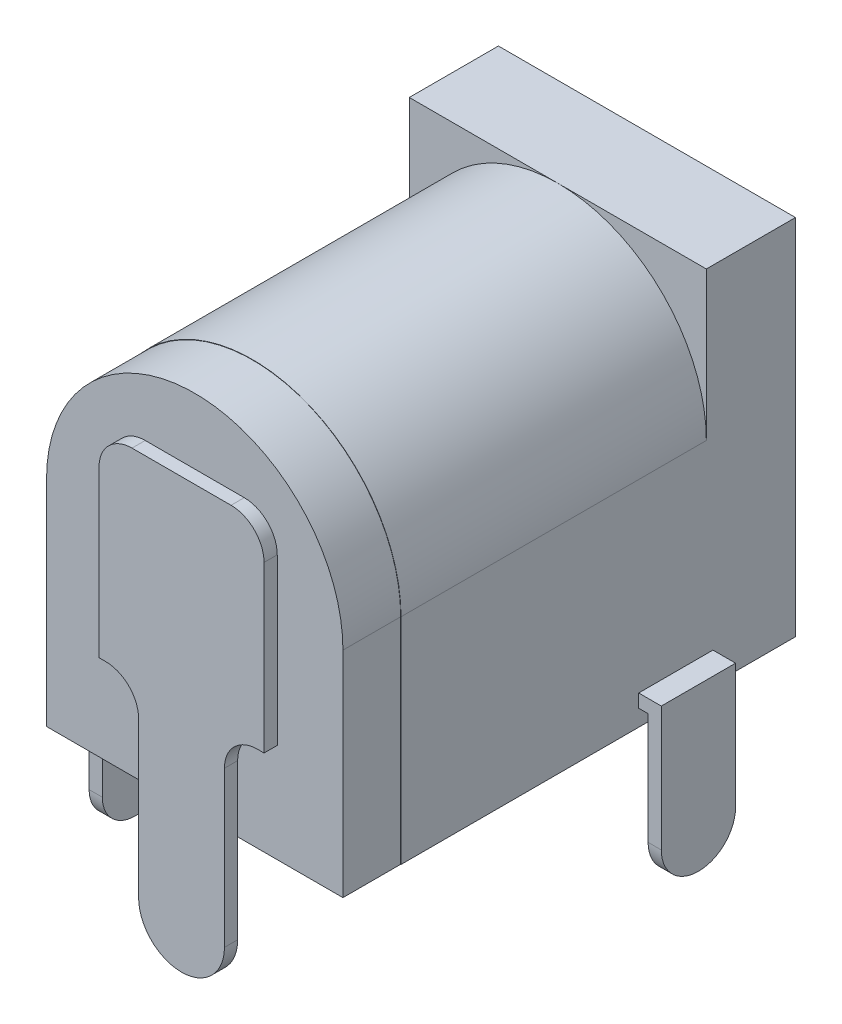
from build123d import *

# Parameters (mm, degrees)
EXTRUSION1_DEPTH        = 9.25
EXTRUSION2_DEPTH        = 1.75
ESQUISSE3_W             = 9
ESQUISSE3_H             = 11
EXTRUSION3_DEPTH        = 2.7
ESQUISSE5_R             = 3.1
ENL_V_MAT_EXTRU_1_DEPTH = 10
ESQUISSE6_R             = 1
EXTRUSION4_DEPTH        = 8
CONG_1_R                = 0.99
EXTRUSION5_DEPTH        = 0.4
ESQUISSE8_W             = 2.25
ESQUISSE8_H             = 0.4
CONG_2_R                = 1.124
ESQUISSE10_W            = 2
ESQUISSE10_H            = 0.4
CONG_3_R                = 0.99


with BuildPart() as part:
    # Esquisse1 → Extrusion1 (new body)
    with BuildSketch(Plane.XY):
        with BuildLine():
            Line((4.5, 6.5), (4.5, 0))
            Line((4.5, 0), (-4.5, 0))
            Line((-4.5, 0), (-4.5, 6.5))
            ThreePointArc((-4.5, 6.5), (0, 11), (4.5, 6.5))
        make_face()
    extrude(amount=EXTRUSION1_DEPTH)

    # Esquisse2 → Extrusion2 (add)
    with BuildSketch(Plane.XY.offset(9.25)):
        with BuildLine():
            Line((4.489996356, 6.494279339), (4.490003644, 0))
            Line((4.490003644, 0), (-4.49, 0))
            Line((-4.49, 0), (-4.49, 6.5))
            ThreePointArc((-4.49, 6.5), (0.002860331, 10.989999089), (4.489996356, 6.494279339))
        make_face()
    extrude(amount=EXTRUSION2_DEPTH)

    # Esquisse3 → Extrusion3 (add)
    with BuildSketch(Plane(origin=(0, 0, 0), x_dir=(-1, 0, 0), z_dir=(0, 0, -1))):
        with Locations((0, 5.5)):
            Rectangle(ESQUISSE3_W, ESQUISSE3_H)
    extrude(amount=EXTRUSION3_DEPTH)

    # Esquisse5 → Enlèv. mat.-Extru.1 (cut)
    with BuildSketch(Plane(origin=(0, 0, -2.7), x_dir=(-1, 0, 0), z_dir=(0, 0, -1))):
        with Locations((0, 6.5)):
            Circle(ESQUISSE5_R)
    extrude(amount=-ENL_V_MAT_EXTRU_1_DEPTH, mode=Mode.SUBTRACT)

    # Esquisse6 → Extrusion4 (add)
    with BuildSketch(Plane(origin=(0, 0, 7.3), x_dir=(-1, 0, 0), z_dir=(0, 0, -1))):
        with Locations((0, 6.5)):
            Circle(ESQUISSE6_R)
    extrude(amount=EXTRUSION4_DEPTH)

    # Congé1
    cong_1_edges = [part.edges().sort_by_distance(p)[0] for p in [
        (1, 6.5, -0.7),
    ]]
    fillet(cong_1_edges, radius=CONG_1_R)

    # Esquisse7 → Extrusion5 (add)
    with BuildSketch(Plane.XY.offset(11)):
        with BuildLine():
            Line((1.5, 9), (-1.5, 9))
            ThreePointArc((-1.5, 9), (-2.207106781, 8.707106781), (-2.5, 8))
            Line((-2.5, 8), (-2.5, 3))
            Line((-2.5, 3), (-2.3, 3))
            ThreePointArc((-2.3, 3), (-1.592893219, 2.707106781), (-1.3, 2))
            Line((-1.3, 2), (-1.3, -2.7))
            ThreePointArc((-1.3, -2.7), (0, -4), (1.3, -2.7))
            Line((1.3, -2.7), (1.3, 2))
            ThreePointArc((1.3, 2), (1.592893219, 2.707106781), (2.3, 3))
            Line((2.3, 3), (2.5, 3))
            Line((2.5, 3), (2.5, 8))
            ThreePointArc((2.5, 8), (2.207106781, 8.707106781), (1.5, 9))
        make_face()
    extrude(amount=EXTRUSION5_DEPTH)

    # Balayage1: sweep along a path in Esquisse9
    with BuildLine(Plane.XY.offset(0.8)) as balayage1_path:
        Line((4.5, 0.714543307), (5, 0.714543307))
        Line((5, 0.714543307), (5, -4))
    # Esquisse8 → Balayage1 (sweep)
    with BuildSketch(Plane(origin=(4.5, 0, 0), x_dir=(0, 0, -1), z_dir=(1, 0, 0))):
        with Locations((-0.925, 0.7)):
            Rectangle(ESQUISSE8_W, ESQUISSE8_H)
    sweep(path=balayage1_path.line, transition=Transition.RIGHT)

    # Congé2
    cong_2_edges = [part.edges().sort_by_distance(p)[0] for p in [
        (4.985456693, -4, -0.2),
        (4.985456693, -4, 2.05),
    ]]
    fillet(cong_2_edges, radius=CONG_2_R)

    # Balayage2: sweep along a path in Esquisse11
    with BuildLine(Plane.XY.offset(8)) as balayage2_path:
        Line((-4.5, 4.8), (-5, 4.8))
        Line((-5, 4.8), (-5, -4))
    # Esquisse10 → Balayage2 (sweep)
    with BuildSketch(Plane.ZY.offset(4.5)):
        with Locations((8, 4.8)):
            Rectangle(ESQUISSE10_W, ESQUISSE10_H)
    sweep(path=balayage2_path.line, transition=Transition.RIGHT)

    # Congé3
    cong_3_edges = [part.edges().sort_by_distance(p)[0] for p in [
        (-5, -4, 9),
        (-5, -4, 7),
    ]]
    fillet(cong_3_edges, radius=CONG_3_R)


solid = part.part
